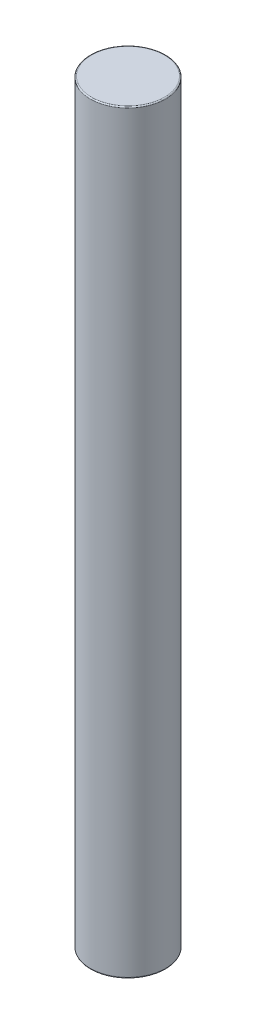
from build123d import *

# Parameters (mm, degrees)
SKETCH1_R      = 1.6
EXTRUDE1_DEPTH = 32.1
FILLET1_R      = 0.05


with BuildPart() as part:
    # Sketch1 → Extrude1 (new body)
    with BuildSketch(Plane(origin=(0, 0, 0), x_dir=(1, 0, 0), z_dir=(0, 1, 0))):
        Circle(SKETCH1_R)
    extrude(amount=EXTRUDE1_DEPTH)

    # Fillet1
    fillet1_edges = [part.edges().sort_by_distance(p)[0] for p in [
        (-1.6, 0, 0),
        (-1.6, 32.1, 0),
    ]]
    fillet(fillet1_edges, radius=FILLET1_R)


solid = part.part
